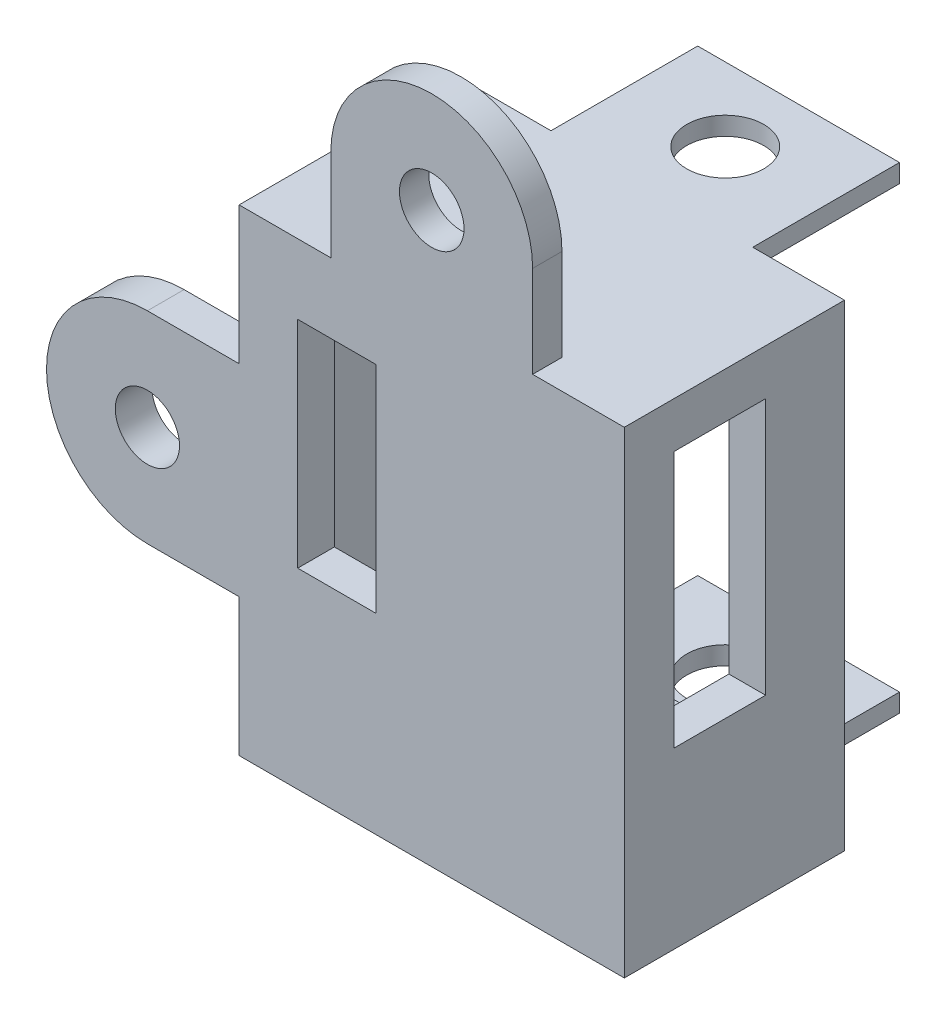
from build123d import *

# Parameters (mm, degrees)
SKETCH1_W           = 21
SKETCH1_H           = 26
SKETCH1_W_2         = 17
SKETCH1_H_2         = 21
BOSS_EXTRUDE1_DEPTH = 10
SKETCH2_W           = 21
SKETCH2_H           = 26
BOSS_EXTRUDE2_DEPTH = 2
SKETCH4_W           = 5
SKETCH4_H           = 14
CUT_EXTRUDE2_DEPTH  = 2
SKETCH6_R           = 1.76
BOSS_EXTRUDE3_DEPTH = 1.6
SKETCH9_R           = 1.76
BOSS_EXTRUDE5_DEPTH = 2
SKETCH14_W          = 11
SKETCH14_H          = 1
BOSS_EXTRUDE8_DEPTH = 8
SKETCH16_R          = 2.1
CUT_EXTRUDE3_DEPTH  = 39
CUT_EXTRUDE4_DEPTH  = 10
SKETCH18_R          = 1.75
BOSS_EXTRUDE9_DEPTH = 2
SKETCH19_W          = 4.280254221
SKETCH19_H          = 11.747931796
CUT_EXTRUDE5_DEPTH  = 10


with BuildPart() as part:
    # Sketch1 → Boss-Extrude1 (new body)
    with BuildSketch(Plane.XY):
        Rectangle(SKETCH1_W, SKETCH1_H)
        Rectangle(SKETCH1_W_2, SKETCH1_H_2, mode=Mode.SUBTRACT)
    extrude(amount=BOSS_EXTRUDE1_DEPTH)

    # Sketch2 → Boss-Extrude2 (add)
    with BuildSketch(Plane.XY.offset(10)):
        Rectangle(SKETCH2_W, SKETCH2_H)
    extrude(amount=BOSS_EXTRUDE2_DEPTH)

    # Sketch4 → Cut-Extrude2 (cut)
    with BuildSketch(Plane(origin=(10.5, 0, 0), x_dir=(0, 0, -1), z_dir=(1, 0, 0))):
        with Locations((-6.8, 3.5)):
            Rectangle(SKETCH4_W, SKETCH4_H)
    extrude(amount=-CUT_EXTRUDE2_DEPTH, mode=Mode.SUBTRACT)

    # Sketch6 → Boss-Extrude3 (add)
    with BuildSketch(Plane.XY.offset(12)):
        with BuildLine():
            Line((0, 13), (5.5, 13))
            Line((5.5, 13), (5.5, 18))
            ThreePointArc((5.5, 18), (0, 23.5), (-5.5, 18))
            Line((-5.5, 18), (-5.5, 13))
            Line((-5.5, 13), (0, 13))
        make_face()
        with Locations((0, 18)):
            Circle(SKETCH6_R, mode=Mode.SUBTRACT)
    extrude(amount=-BOSS_EXTRUDE3_DEPTH)

    # Sketch9 → Boss-Extrude5 (add)
    with BuildSketch(Plane.XY.offset(12)):
        with BuildLine():
            Line((0, -13), (-5.5, -13))
            Line((-5.5, -13), (-5.5, -18))
            ThreePointArc((-5.5, -18), (0, -23.5), (5.5, -18))
            Line((5.5, -18), (5.5, -13))
            Line((5.5, -13), (0, -13))
        make_face()
        with Locations((0, -18)):
            Circle(SKETCH9_R, mode=Mode.SUBTRACT)
    extrude(amount=-BOSS_EXTRUDE5_DEPTH)

    # Sketch14 → Boss-Extrude8 (add)
    with BuildSketch(Plane(origin=(0, 0, 0), x_dir=(-1, 0, 0), z_dir=(0, 0, -1))):
        with Locations((0, -12.5)):
            Rectangle(SKETCH14_W, SKETCH14_H)
        with Locations((0, 12.5)):
            Rectangle(SKETCH14_W, SKETCH14_H)
    extrude(amount=BOSS_EXTRUDE8_DEPTH)

    # Sketch16 → Cut-Extrude3 (cut)
    with BuildSketch(Plane(origin=(0, 13, 0), x_dir=(1, 0, 0), z_dir=(0, 1, 0))):
        with Locations((0, 4)):
            Circle(SKETCH16_R)
    extrude(amount=-CUT_EXTRUDE3_DEPTH, mode=Mode.SUBTRACT)

    # Sketch17 → Cut-Extrude4 (cut)
    with BuildSketch(Plane(origin=(0, 0, 10), x_dir=(-1, 0, 0), z_dir=(0, 0, -1))):
        with BuildLine():
            Line((-5.5, -18), (-5.5, -13))
            Line((-5.5, -13), (5.5, -13))
            Line((5.5, -13), (5.5, -18))
            ThreePointArc((5.5, -18), (0, -23.5), (-5.5, -18))
        make_face()
    extrude(amount=-CUT_EXTRUDE4_DEPTH, mode=Mode.SUBTRACT)

    # Sketch18 → Boss-Extrude9 (add)
    with BuildSketch(Plane.XY.offset(12)):
        with BuildLine():
            Line((-10.5, 0), (-10.5, 5.5))
            Line((-10.5, 5.5), (-15.5, 5.5))
            ThreePointArc((-15.5, 5.5), (-21, 0), (-15.5, -5.5))
            Line((-15.5, -5.5), (-10.5, -5.5))
            Line((-10.5, -5.5), (-10.5, 0))
        make_face()
        with Locations((-15.5, 0)):
            Circle(SKETCH18_R, mode=Mode.SUBTRACT)
    extrude(amount=-BOSS_EXTRUDE9_DEPTH)

    # Sketch19 → Cut-Extrude5 (cut)
    with BuildSketch(Plane(origin=(0, 0, 10), x_dir=(-1, 0, 0), z_dir=(0, 0, -1))):
        with Locations((5.165781479, 3.32004636)):
            Rectangle(SKETCH19_W, SKETCH19_H)
    extrude(amount=-CUT_EXTRUDE5_DEPTH, mode=Mode.SUBTRACT)


solid = part.part
